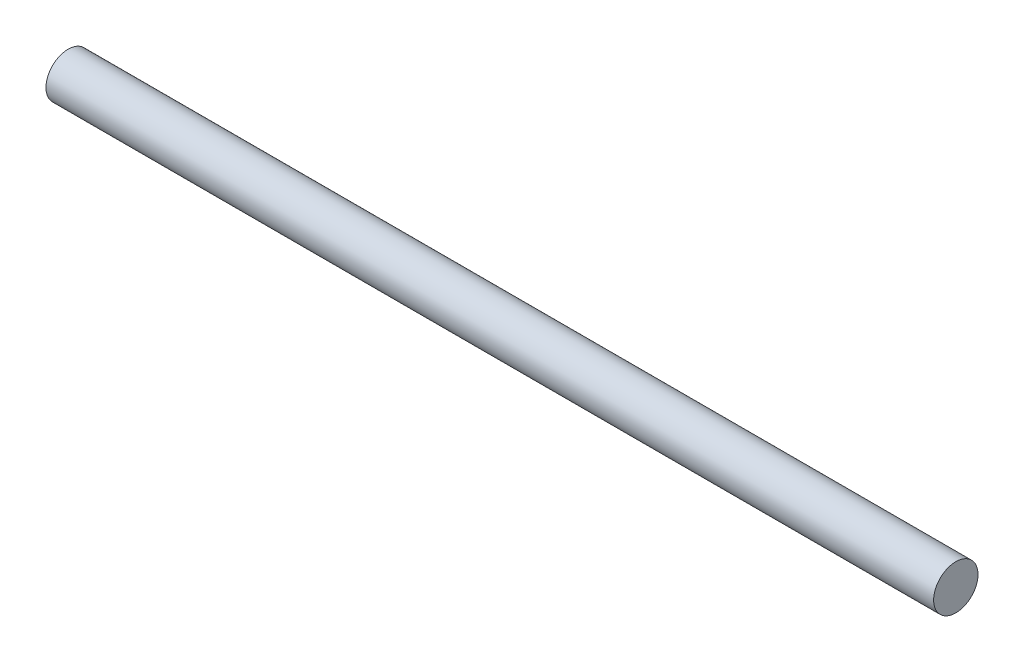
from build123d import *

# Parameters (mm, degrees)
SKETCH1_R           = 1
BOSS_EXTRUDE1_DEPTH = 20


with BuildPart() as part:
    # Sketch1 → Boss-Extrude1 (new body, symmetric)
    with BuildSketch(Plane(origin=(0, 0, 0), x_dir=(0, 0, -1), z_dir=(1, 0, 0))):
        Circle(SKETCH1_R)
    extrude(amount=BOSS_EXTRUDE1_DEPTH, both=True)


solid = part.part
